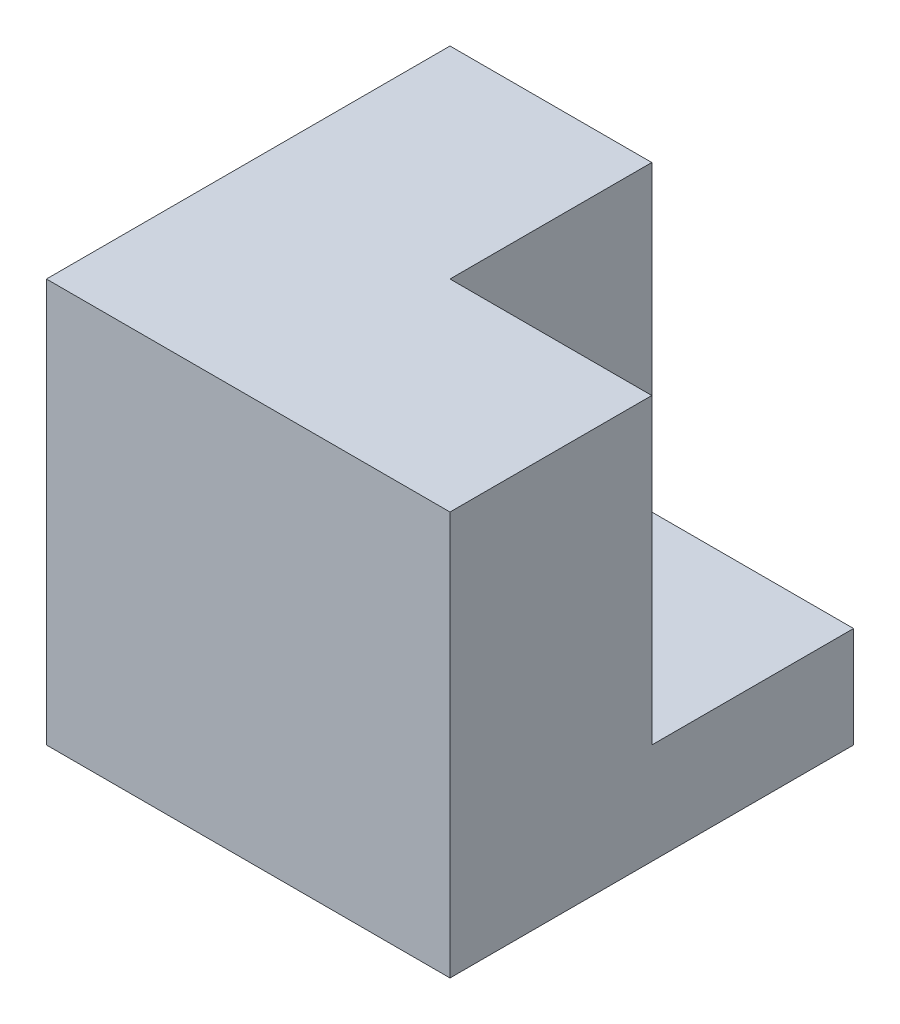
from build123d import *

# Parameters (mm, degrees)
SKETCH1_W           = 76.2
SKETCH1_H           = 76.2
BOSS_EXTRUDE1_DEPTH = 76.2
SKETCH2_W           = 38.1
SKETCH2_H           = 57.15
CUT_EXTRUDE1_DEPTH  = 38.1


with BuildPart() as part:
    # Sketch1 → Boss-Extrude1 (new body)
    with BuildSketch(Plane.XY):
        with Locations((38.1, 38.1)):
            Rectangle(SKETCH1_W, SKETCH1_H)
    extrude(amount=BOSS_EXTRUDE1_DEPTH)

    # Sketch2 → Cut-Extrude1 (cut)
    with BuildSketch(Plane(origin=(76.2, 0, 0), x_dir=(0, 0, -1), z_dir=(1, 0, 0))):
        with Locations((-19.05, 47.625)):
            Rectangle(SKETCH2_W, SKETCH2_H)
    extrude(amount=-CUT_EXTRUDE1_DEPTH, mode=Mode.SUBTRACT)


solid = part.part
